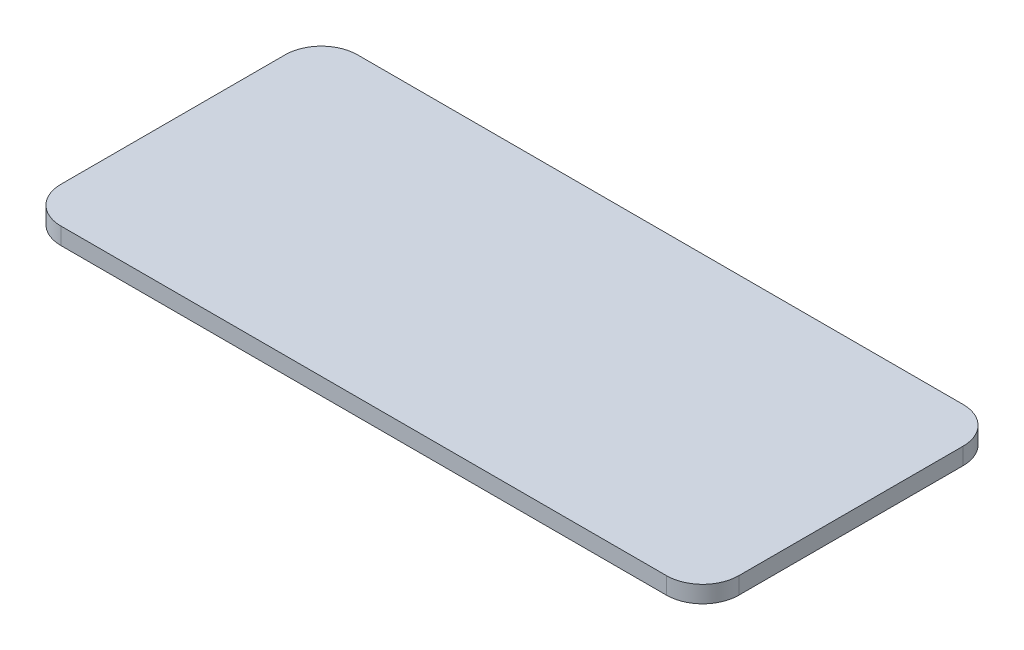
from build123d import *

# Parameters (mm, degrees)
SKETCH1_W           = 64
SKETCH1_H           = 28
BOSS_EXTRUDE1_DEPTH = 1.6
FILLET1_R           = 3.41


with BuildPart() as part:
    # Sketch1 → Boss-Extrude1 (new body)
    with BuildSketch(Plane(origin=(0, 0, 0), x_dir=(1, 0, 0), z_dir=(0, 1, 0))):
        Rectangle(SKETCH1_W, SKETCH1_H)
    extrude(amount=BOSS_EXTRUDE1_DEPTH)

    # Fillet1
    fillet1_edges = [part.edges().sort_by_distance(p)[0] for p in [
        (-32, 0.8, -14),
        (32, 0.8, -14),
        (32, 0.8, 14),
        (-32, 0.8, 14),
    ]]
    fillet(fillet1_edges, radius=FILLET1_R)


solid = part.part
